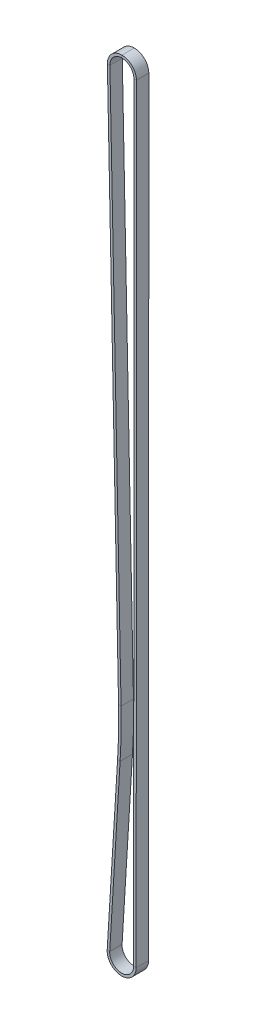
from build123d import *

# Parameters (mm, degrees)
SKETCH3_W = 7.366
SKETCH3_H = 1.5


with BuildPart() as part:
    # Sweep1: sweep along a path in Sketch2
    with BuildLine(Plane.XY) as sweep1_path:
        Line((7.091056719, -457.202005016), (7.218056719, -0.002005016))
        ThreePointArc((7.218056719, -0.002005016), (-0.072338406, 7.217694506), (-7.216566601, -0.146674154))
        Line((-7.216566601, -0.146674154), (-0.57395254, -326.972262728))
        ThreePointArc((-0.57395254, -326.972262728), (-0.574097453, -341.338325894), (-1.158260966, -355.692507303))
        Line((-1.158260966, -355.692507303), (-7.331629374, -456.759929099))
        ThreePointArc((-7.331629374, -456.759929099), (-0.348139893, -464.414668667), (7.091056719, -457.202005016))
    # Sketch3 → Sweep1 (sweep)
    with BuildSketch(Plane(origin=(0, 0, 0), x_dir=(0, 0, -1), z_dir=(1, 0, 0))):
        with Locations((3.683, 7.887099691)):
            Rectangle(SKETCH3_W, SKETCH3_H)
    sweep(path=sweep1_path.line)


solid = part.part
